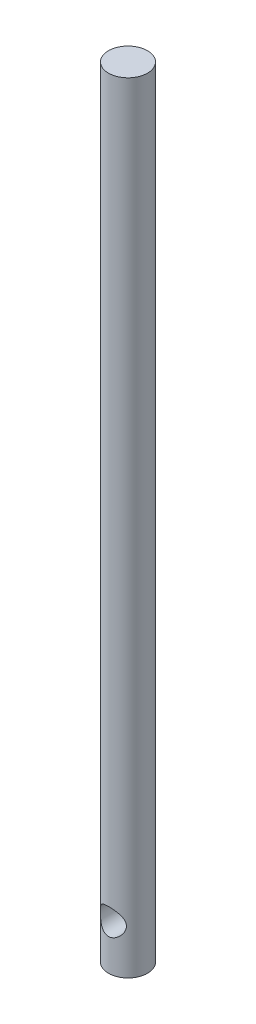
from build123d import *

# Parameters (mm, degrees)
SKETCH1_R               = 1.5
BOSS_EXTRUDE1_DEPTH     = 60
SKETCH6_R               = 1
CUT_EXTRUDE3_DEPTH      = 2.5
CUT_EXTRUDE3_DEPTH_BACK = 2.5


with BuildPart() as part:
    # Sketch1 → Boss-Extrude1 (new body)
    with BuildSketch(Plane(origin=(0, 0, 0), x_dir=(1, 0, 0), z_dir=(0, 1, 0))):
        Circle(SKETCH1_R)
    extrude(amount=BOSS_EXTRUDE1_DEPTH)

    # Sketch6 → Cut-Extrude3 (cut, two sides)
    with BuildSketch(Plane.XY) as cut_extrude3_sk:
        with Locations((0, 3.458689927)):
            Circle(SKETCH6_R)
    extrude(amount=CUT_EXTRUDE3_DEPTH, mode=Mode.SUBTRACT)
    extrude(cut_extrude3_sk.sketch, amount=-CUT_EXTRUDE3_DEPTH_BACK, mode=Mode.SUBTRACT)


solid = part.part
